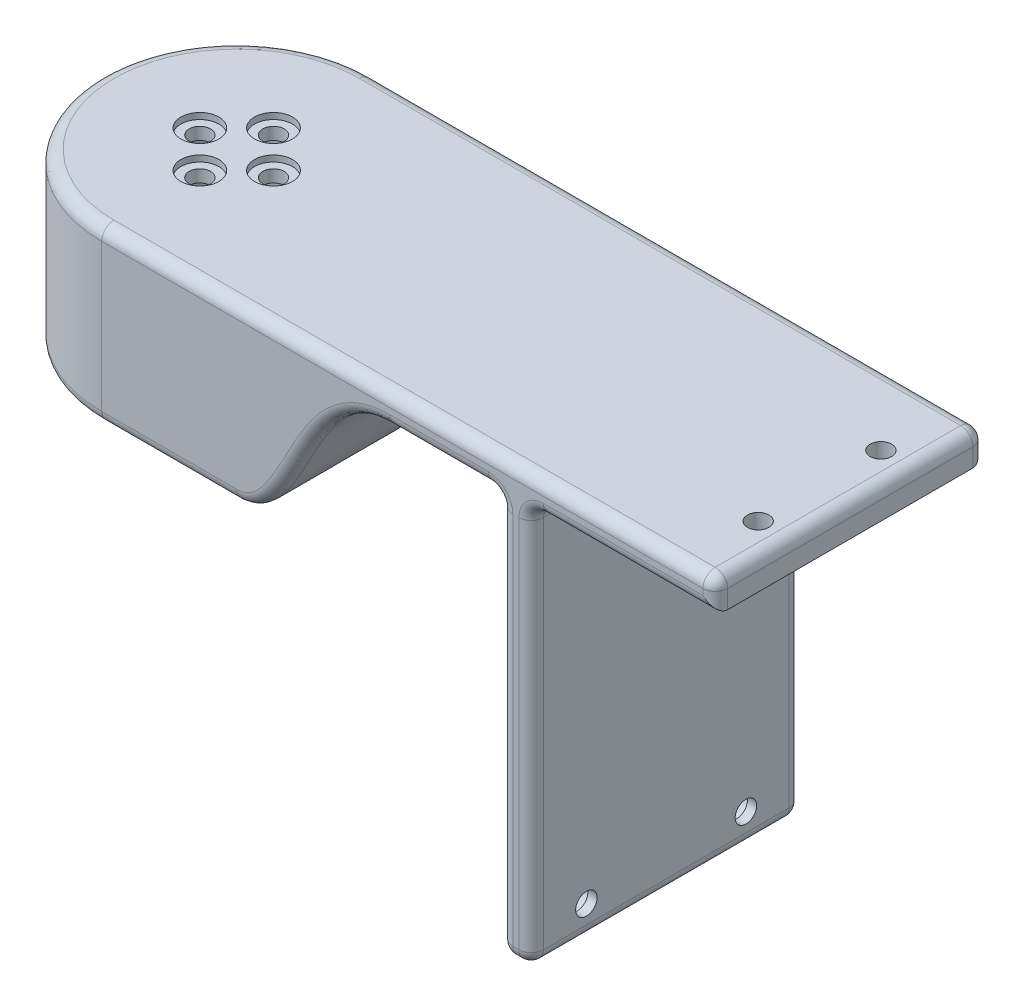
from build123d import *

# Parameters (mm, degrees)
SKETCH1_R           = 22
BOSS_EXTRUDE1_DEPTH = 3
SKETCH2_R           = 22
SKETCH2_R_2         = 15.5
BOSS_EXTRUDE2_DEPTH = 25
SKETCH3_R           = 3.1
SKETCH3_R_2         = 1.75
CUT_EXTRUDE1_DEPTH  = 1
SKETCH3_2_R         = 1.75
CUT_EXTRUDE2_DEPTH  = 3
CIRPATTERN1_COUNT   = 4
FILLET1_R           = 2
FILLET2_R           = 4
BOSS_EXTRUDE3_DEPTH = 5
BOSS_EXTRUDE5_REACH = 46
SKETCH11_W          = 44
SKETCH11_H          = 23
BOSS_EXTRUDE6_START = -22
BOSS_EXTRUDE6_DEPTH = 44
SKETCH15_W          = 5
SKETCH15_H          = 44
BOSS_EXTRUDE7_DEPTH = 65
FILLET6_R           = 2
CUT_EXTRUDE4_REACH  = 94
SKETCH16_R          = 1.75
CUT_EXTRUDE3_REACH  = 72
SKETCH14_R          = 1.75
SKETCH17_R          = 2.2
CUT_EXTRUDE5_DEPTH  = 3.5


with BuildPart() as part:
    # Sketch1 → Boss-Extrude1 (new body)
    with BuildSketch(Plane(origin=(0, 0, 0), x_dir=(1, 0, 0), z_dir=(0, 1, 0))):
        Circle(SKETCH1_R)
    extrude(amount=-BOSS_EXTRUDE1_DEPTH)

    # Sketch2 → Boss-Extrude2 (add)
    with BuildSketch(Plane.XZ.offset(3)):
        Circle(SKETCH2_R)
        Circle(SKETCH2_R_2, mode=Mode.SUBTRACT)
    extrude(amount=BOSS_EXTRUDE2_DEPTH)

    # Sketch3 → Cut-Extrude1 (cut)
    with BuildSketch(Plane(origin=(0, 0, 0), x_dir=(1, 0, 0), z_dir=(0, 1, 0))):
        with Locations((0, 6)):
            Circle(SKETCH3_R)
        with Locations((0, 6)):
            Circle(SKETCH3_R_2, mode=Mode.SUBTRACT)
    cut_extrude1 = extrude(amount=-CUT_EXTRUDE1_DEPTH, mode=Mode.SUBTRACT)

    # Sketch3_2 → Cut-Extrude2 (cut)
    with BuildSketch(Plane(origin=(0, 0, 0), x_dir=(1, 0, 0), z_dir=(0, 1, 0))):
        with Locations((0, 6)):
            Circle(SKETCH3_2_R)
    cut_extrude2 = extrude(amount=-CUT_EXTRUDE2_DEPTH, mode=Mode.SUBTRACT)

    # CirPattern1: Cut-Extrude1, Cut-Extrude2 ×4 about axis
    cirpattern1_axis = Axis((0, 0, 0), (0, 1, 0))
    for i in range(1, CIRPATTERN1_COUNT):
        add(cut_extrude1.rotate(cirpattern1_axis, i * 360 / CIRPATTERN1_COUNT), mode=Mode.SUBTRACT)
        add(cut_extrude2.rotate(cirpattern1_axis, i * 360 / CIRPATTERN1_COUNT), mode=Mode.SUBTRACT)

    # Fillet1
    fillet1_edges = [part.edges().sort_by_distance(p)[0] for p in [
        (-15.5, -3, 0),
    ]]
    fillet(fillet1_edges, radius=FILLET1_R)

    # Fillet2
    fillet2_edges = [part.edges().sort_by_distance(p)[0] for p in [
        (-15.5, -28, 0),
    ]]
    fillet(fillet2_edges, radius=FILLET2_R)

    # Sketch5 → Boss-Extrude3 (add)
    with BuildSketch(Plane(origin=(0, 0, 0), x_dir=(1, 0, 0), z_dir=(0, 1, 0))):
        with BuildLine():
            Line((0, 22), (100, 22))
            Line((100, 22), (100, -22))
            Line((100, -22), (0, -22))
            ThreePointArc((0, -22), (22, 0), (0, 22))
        make_face()
    extrude(amount=-BOSS_EXTRUDE3_DEPTH)

    # Sketch11 → Boss-Extrude5 (add, up to next)
    with BuildSketch(Plane(origin=(22, 0, 0), x_dir=(0, 0, -1), z_dir=(1, 0, 0)), mode=Mode.PRIVATE) as boss_extrude5_sk1:
        with Locations((0, -16.5)):
            Rectangle(SKETCH11_W, SKETCH11_H)
    boss_extrude5_tool1 = extrude(boss_extrude5_sk1.sketch, amount=-BOSS_EXTRUDE5_REACH, mode=Mode.PRIVATE) - part.part
    add(boss_extrude5_tool1.solids().sort_by_distance((22, -16.5, 0))[0])
    add(boss_extrude5_tool1.solids().sort_by_distance((22, -16.5, 0))[1])

    # Sketch13 → Boss-Extrude6 (add)
    with BuildSketch(Plane.XY.offset(BOSS_EXTRUDE6_START)):
        with BuildLine():
            Line((22, -28), (22, -5))
            Line((22, -5), (46.99659249, -5))
            add(Edge.make_bspline(
                [(22, -28), (32, -28), (32, -5), (46.99659249, -5)],
                knots=[0, 0, 0, 0, 1, 1, 1, 1], degree=3))
        make_face()
    extrude(amount=BOSS_EXTRUDE6_DEPTH)

    # Sketch15 → Boss-Extrude7 (add)
    with BuildSketch(Plane.XZ.offset(5)):
        with Locations((67.5, 0)):
            Rectangle(SKETCH15_W, SKETCH15_H)
    extrude(amount=BOSS_EXTRUDE7_DEPTH)

    # Fillet6
    fillet6_edges = [part.edges().sort_by_distance(p)[0] for p in [
        (55.998296245, -5, 22),
        (33.359605405, -15.173106439, -22),
        (33.359605405, -15.173106439, 22),
        (85, -5, 22),
        (55.998296245, -5, -22),
        (65, -5, 0),
        (65, -37.5, 22),
        (65, -37.5, -22),
        (70, -5, 0),
        (70, -37.5, -22),
        (70, -37.5, 22),
        (65, -70, 0),
        (67.5, -70, -22),
        (70, -70, 0),
        (67.5, -70, 22),
        (-22, 0, 0),
        (85, -5, -22),
        (100, -2.5, -22),
        (100, -2.5, 22),
        (50, 0, 22),
        (100, 0, 0),
        (50, 0, -22),
        (11, -28, -22),
        (-22, -28, -2.2e-08),
        (10.999999978, -28, 22),
    ]]
    fillet(fillet6_edges, radius=FILLET6_R)

    # Sketch16 → Cut-Extrude4 (cut, up to next)
    with BuildSketch(Plane(origin=(70, 0, 0), x_dir=(0, 0, -1), z_dir=(1, 0, 0)), mode=Mode.PRIVATE) as cut_extrude4_sk1:
        with Locations((-13, -65)):
            Circle(SKETCH16_R)
    cut_extrude4_tool1 = extrude(cut_extrude4_sk1.sketch, amount=-CUT_EXTRUDE4_REACH, mode=Mode.PRIVATE) & part.part
    add(cut_extrude4_tool1.solids().sort_by_distance((70, -65, 13))[0], mode=Mode.SUBTRACT)
    # Sketch16 → Cut-Extrude4 (cut, up to next)
    with BuildSketch(Plane(origin=(70, 0, 0), x_dir=(0, 0, -1), z_dir=(1, 0, 0)), mode=Mode.PRIVATE) as cut_extrude4_sk2:
        with Locations((13, -65)):
            Circle(SKETCH16_R)
    cut_extrude4_tool2 = extrude(cut_extrude4_sk2.sketch, amount=-CUT_EXTRUDE4_REACH, mode=Mode.PRIVATE) & part.part
    add(cut_extrude4_tool2.solids().sort_by_distance((70, -65, -13))[0], mode=Mode.SUBTRACT)

    # Sketch14 → Cut-Extrude3 (cut, up to next)
    with BuildSketch(Plane(origin=(0, 0, 0), x_dir=(1, 0, 0), z_dir=(0, 1, 0)), mode=Mode.PRIVATE) as cut_extrude3_sk1:
        with Locations((95, 10)):
            Circle(SKETCH14_R)
    cut_extrude3_tool1 = extrude(cut_extrude3_sk1.sketch, amount=-CUT_EXTRUDE3_REACH, mode=Mode.PRIVATE) & part.part
    add(cut_extrude3_tool1.solids().sort_by_distance((95, 0, -10))[0], mode=Mode.SUBTRACT)
    # Sketch14 → Cut-Extrude3 (cut, up to next)
    with BuildSketch(Plane(origin=(0, 0, 0), x_dir=(1, 0, 0), z_dir=(0, 1, 0)), mode=Mode.PRIVATE) as cut_extrude3_sk2:
        with Locations((95, -10)):
            Circle(SKETCH14_R)
    cut_extrude3_tool2 = extrude(cut_extrude3_sk2.sketch, amount=-CUT_EXTRUDE3_REACH, mode=Mode.PRIVATE) & part.part
    add(cut_extrude3_tool2.solids().sort_by_distance((95, 0, 10))[0], mode=Mode.SUBTRACT)

    # Sketch17 → Cut-Extrude5 (cut)
    with BuildSketch(Plane.ZY.offset(-65)):
        with Locations((-13, -65)):
            Circle(SKETCH17_R)
        with Locations((13, -65)):
            Circle(SKETCH17_R)
    extrude(amount=-CUT_EXTRUDE5_DEPTH, mode=Mode.SUBTRACT)


solid = part.part
